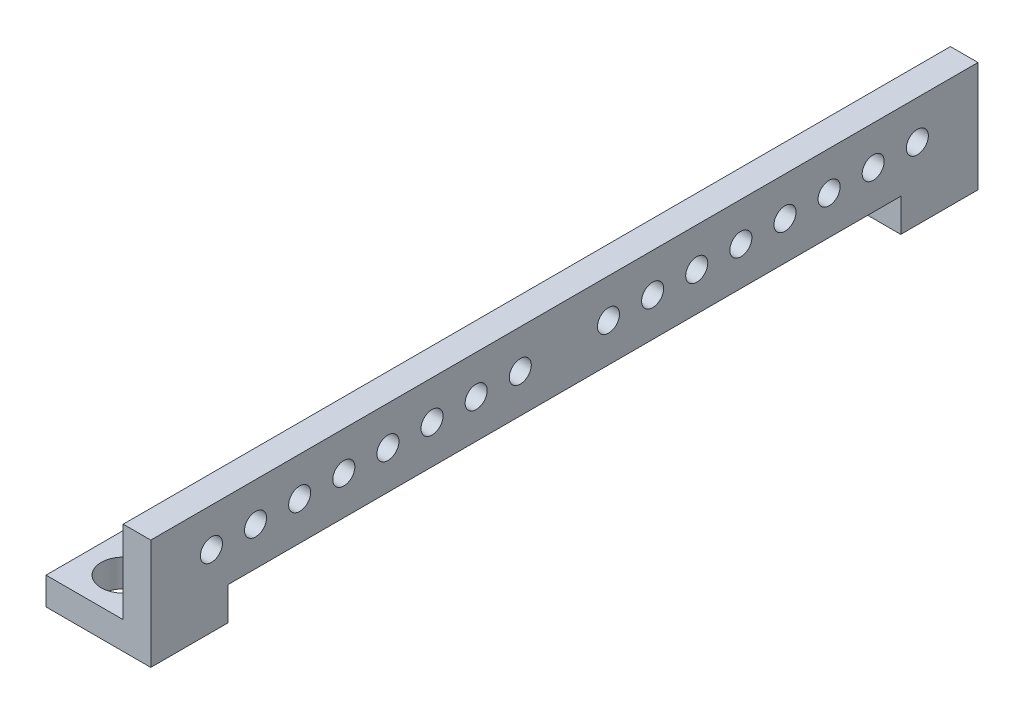
from build123d import *

# Parameters (mm, degrees)
SKETCH1_R           = 2
BOSS_EXTRUDE1_DEPTH = 5
SKETCH2_W           = 14
SKETCH2_H           = 5
BOSS_EXTRUDE2_DEPTH = 14
SKETCH3_R           = 4
CUT_EXTRUDE1_DEPTH  = 25


with BuildPart() as part:
    # Sketch1 → Boss-Extrude1 (new body)
    with BuildSketch(Plane(origin=(0, 0, 0), x_dir=(0, 0, -1), z_dir=(1, 0, 0))):
        Polygon((61, 0), (75, 0), (75, 20), (-75, 20), (-75, 0), (-61, 0), (-61, 6), (61, 6), align=None)
        with Locations((-16, 13)):
            Circle(SKETCH1_R, mode=Mode.SUBTRACT)
        with Locations((-24, 13)):
            Circle(SKETCH1_R, mode=Mode.SUBTRACT)
        with Locations((-32, 13)):
            Circle(SKETCH1_R, mode=Mode.SUBTRACT)
        with Locations((-40, 13)):
            Circle(SKETCH1_R, mode=Mode.SUBTRACT)
        with Locations((16, 13)):
            Circle(SKETCH1_R, mode=Mode.SUBTRACT)
        with Locations((24, 13)):
            Circle(SKETCH1_R, mode=Mode.SUBTRACT)
        with Locations((32, 13)):
            Circle(SKETCH1_R, mode=Mode.SUBTRACT)
        with Locations((40, 13)):
            Circle(SKETCH1_R, mode=Mode.SUBTRACT)
        with Locations((-48, 13)):
            Circle(SKETCH1_R, mode=Mode.SUBTRACT)
        with Locations((-56, 13)):
            Circle(SKETCH1_R, mode=Mode.SUBTRACT)
        with Locations((-64, 13)):
            Circle(SKETCH1_R, mode=Mode.SUBTRACT)
        with Locations((48, 13)):
            Circle(SKETCH1_R, mode=Mode.SUBTRACT)
        with Locations((56, 13)):
            Circle(SKETCH1_R, mode=Mode.SUBTRACT)
        with Locations((64, 13)):
            Circle(SKETCH1_R, mode=Mode.SUBTRACT)
        with Locations((-8, 13)):
            Circle(SKETCH1_R, mode=Mode.SUBTRACT)
        with Locations((8, 13)):
            Circle(SKETCH1_R, mode=Mode.SUBTRACT)
    extrude(amount=BOSS_EXTRUDE1_DEPTH)

    # Sketch2 → Boss-Extrude2 (add)
    with BuildSketch(Plane.ZY):
        with Locations((-68, 2.5)):
            Rectangle(SKETCH2_W, SKETCH2_H)
        with Locations((68, 2.5)):
            Rectangle(SKETCH2_W, SKETCH2_H)
    extrude(amount=BOSS_EXTRUDE2_DEPTH)

    # Sketch3 → Cut-Extrude1 (cut)
    with BuildSketch(Plane(origin=(0, 0, 0), x_dir=(-1, 0, 0), z_dir=(0, -1, 0))):
        with Locations((7, -68)):
            Circle(SKETCH3_R)
        with Locations((7, 68)):
            Circle(SKETCH3_R)
    extrude(amount=-CUT_EXTRUDE1_DEPTH, mode=Mode.SUBTRACT)


solid = part.part
